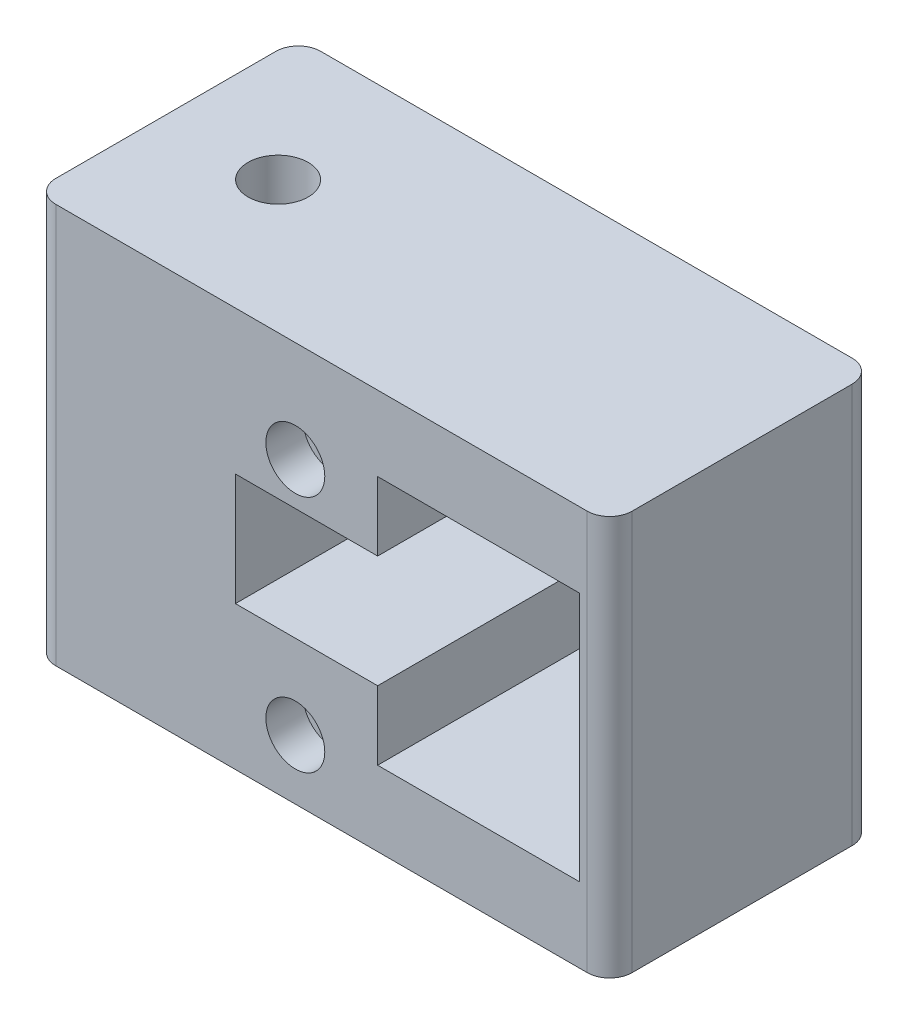
from build123d import *

# Parameters (mm, degrees)
SKETCH1_W           = 97.79
SKETCH1_H           = 67.818
BOSS_EXTRUDE1_DEPTH = 42.418
SKETCH2_W           = 97.79
SKETCH2_H           = 67.818
BOSS_EXTRUDE2_DEPTH = 2.54
SKETCH3_R           = 4.064
CUT_EXTRUDE1_DEPTH  = 68.818
SKETCH4_R           = 5
CUT_EXTRUDE2_DEPTH  = 6.35
SKETCH5_R           = 5.1
CUT_EXTRUDE3_DEPTH  = 15.24
FILLET1_R           = 3.81


with BuildPart() as part:
    # Sketch1 → Boss-Extrude1 (new body)
    with BuildSketch(Plane.XY):
        with Locations((-1.905, 21.209)):
            Rectangle(SKETCH1_W, SKETCH1_H)
        Polygon((7.62, 30.734), (7.62, 42.418), (41.91, 42.418), (41.91, 0), (7.62, 0), (7.62, 11.684), (-16.51, 11.684), (-16.51, 30.734), align=None, mode=Mode.SUBTRACT)
    extrude(amount=BOSS_EXTRUDE1_DEPTH)

    # Sketch2 → Boss-Extrude2 (add)
    with BuildSketch(Plane(origin=(0, 0, 0), x_dir=(-1, 0, 0), z_dir=(0, 0, -1))):
        with Locations((1.905, 21.209)):
            Rectangle(SKETCH2_W, SKETCH2_H)
    extrude(amount=BOSS_EXTRUDE2_DEPTH)

    # Sketch3 → Cut-Extrude1 (cut, through all)
    with BuildSketch(Plane.XZ.offset(12.7)):
        with Locations((-31.75, 19.939)):
            Circle(SKETCH3_R)
    extrude(amount=-CUT_EXTRUDE1_DEPTH, mode=Mode.SUBTRACT)

    # Sketch4 → Cut-Extrude2 (cut)
    with BuildSketch(Plane.XY.offset(42.418)):
        with Locations((-6.35, 37.96)):
            Circle(SKETCH4_R)
        with Locations((-6.35, -2.54)):
            Circle(SKETCH4_R)
    extrude(amount=-CUT_EXTRUDE2_DEPTH, mode=Mode.SUBTRACT)

    # Sketch5 → Cut-Extrude3 (cut)
    with BuildSketch(Plane(origin=(0, 55.118, 0), x_dir=(1, 0, 0), z_dir=(0, 1, 0))):
        with Locations((-31.75, -19.939)):
            Circle(SKETCH5_R)
    extrude(amount=-CUT_EXTRUDE3_DEPTH, mode=Mode.SUBTRACT)

    # Fillet1
    fillet1_edges = [part.edges().sort_by_distance(p)[0] for p in [
        (46.99, 21.209, 42.418),
        (46.99, 21.209, -2.54),
        (-50.8, 21.209, -2.54),
        (-50.8, 21.209, 42.418),
    ]]
    fillet(fillet1_edges, radius=FILLET1_R)


solid = part.part
